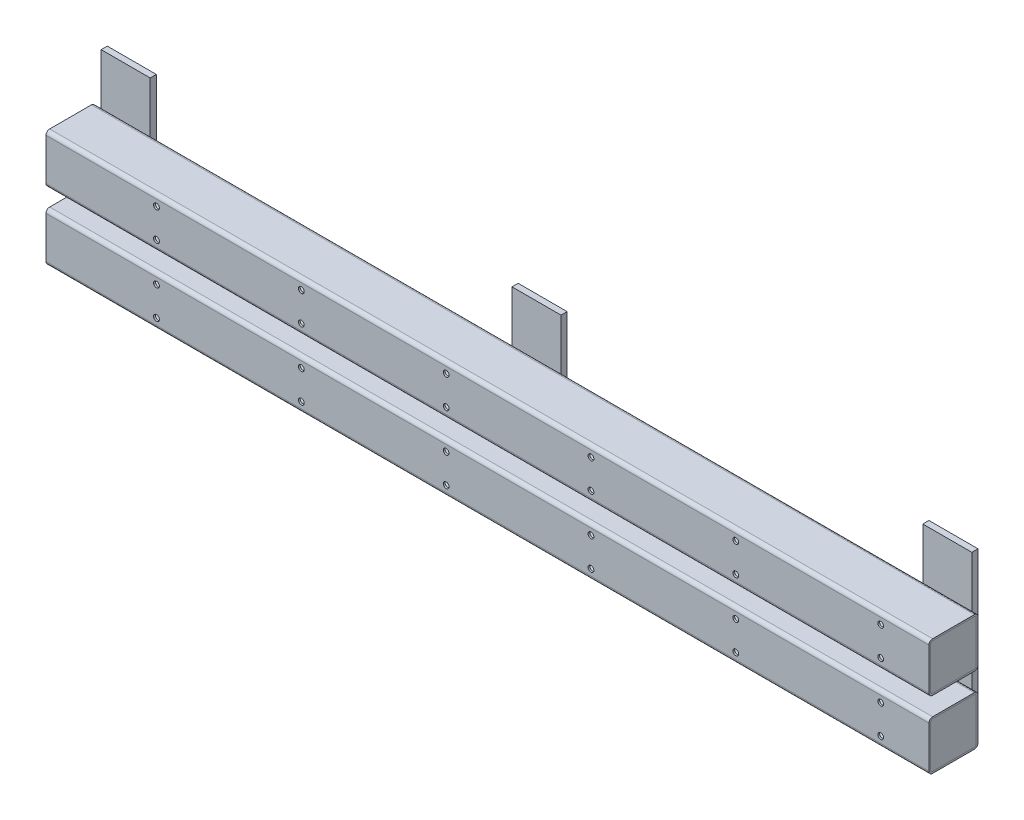
from build123d import *

# Parameters (mm, degrees)
F_2X2_SQUARE_TUBE_2X2X0_725_SQUARE_TUBE_1_DEPTH = 914.4
F_2X2_SQUARE_TUBE_2X2X0_725_SQUARE_TUB_2_DEPTH  = 914.4
BOSS_EXTRUDE1_DEPTH                             = 3
BOSS_EXTRUDE1_2_DEPTH                           = 3
BOSS_EXTRUDE4_DEPTH                             = 6.35
BOSS_EXTRUDE4_2_DEPTH                           = 6.35
SKETCH13_W                                      = 50.8
SKETCH13_H                                      = 171.6
BOSS_EXTRUDE3_DEPTH                             = 6.35
BOSS_EXTRUDE3_2_DEPTH                           = 6.35
BOSS_EXTRUDE3_3_DEPTH                           = 6.35
SKETCH16_R                                      = 3
CUT_EXTRUDE1_DEPTH                              = 1.8415
LPATTERN1_COUNT                                 = 6
LPATTERN1_PITCH                                 = 150
SKETCH18_R                                      = 3
CUT_EXTRUDE2_DEPTH                              = 3


with BuildPart() as part:
    # Sketch15 → 2x2 square tube 2X2X0.725 SQUARE TUBE(1) (new body)
    with BuildSketch(Plane(origin=(0, 70, 0), x_dir=(0, 1, 0), z_dir=(1, 0, 0))):
        with BuildLine():
            Line((-21.59, -25.4), (21.59, -25.4))
            ThreePointArc((21.59, -25.4), (24.284076836, -24.284076836), (25.4, -21.59))
            Line((25.4, -21.59), (25.4, 21.59))
            ThreePointArc((25.4, 21.59), (24.284076836, 24.284076836), (21.59, 25.4))
            Line((21.59, 25.4), (-21.59, 25.4))
            ThreePointArc((-21.59, 25.4), (-24.284076836, 24.284076836), (-25.4, 21.59))
            Line((-25.4, 21.59), (-25.4, -21.59))
            ThreePointArc((-25.4, -21.59), (-24.284076836, -24.284076836), (-21.59, -25.4))
        make_face()
        with BuildLine():
            Line((23.5585, -21.59), (23.5585, 21.59))
            ThreePointArc((23.5585, 21.59), (22.981939699, 22.981939699), (21.59, 23.5585))
            Line((21.59, 23.5585), (-21.59, 23.5585))
            ThreePointArc((-21.59, 23.5585), (-22.981939699, 22.981939699), (-23.5585, 21.59))
            Line((-23.5585, 21.59), (-23.5585, -21.59))
            ThreePointArc((-23.5585, -21.59), (-22.981939699, -22.981939699), (-21.59, -23.5585))
            Line((-21.59, -23.5585), (21.59, -23.5585))
            ThreePointArc((21.59, -23.5585), (22.981939699, -22.981939699), (23.5585, -21.59))
        make_face(mode=Mode.SUBTRACT)
    extrude(amount=F_2X2_SQUARE_TUBE_2X2X0_725_SQUARE_TUBE_1_DEPTH)


with BuildPart() as body_2:
    # Sketch15 on segment 2 (carried to segment 2) → 2x2 square tube 2X2X0.725 SQUARE TUB 2 (new body)
    with BuildSketch(Plane.YZ):
        with BuildLine():
            Line((-21.59, -25.4), (21.59, -25.4))
            ThreePointArc((21.59, -25.4), (24.284076836, -24.284076836), (25.4, -21.59))
            Line((25.4, -21.59), (25.4, 21.59))
            ThreePointArc((25.4, 21.59), (24.284076836, 24.284076836), (21.59, 25.4))
            Line((21.59, 25.4), (-21.59, 25.4))
            ThreePointArc((-21.59, 25.4), (-24.284076836, 24.284076836), (-25.4, 21.59))
            Line((-25.4, 21.59), (-25.4, -21.59))
            ThreePointArc((-25.4, -21.59), (-24.284076836, -24.284076836), (-21.59, -25.4))
        make_face()
        with BuildLine():
            Line((23.5585, -21.59), (23.5585, 21.59))
            ThreePointArc((23.5585, 21.59), (22.981939699, 22.981939699), (21.59, 23.5585))
            Line((21.59, 23.5585), (-21.59, 23.5585))
            ThreePointArc((-21.59, 23.5585), (-22.981939699, 22.981939699), (-23.5585, 21.59))
            Line((-23.5585, 21.59), (-23.5585, -21.59))
            ThreePointArc((-23.5585, -21.59), (-22.981939699, -22.981939699), (-21.59, -23.5585))
            Line((-21.59, -23.5585), (21.59, -23.5585))
            ThreePointArc((21.59, -23.5585), (22.981939699, -22.981939699), (23.5585, -21.59))
        make_face(mode=Mode.SUBTRACT)
    extrude(amount=F_2X2_SQUARE_TUBE_2X2X0_725_SQUARE_TUB_2_DEPTH)


with BuildPart() as body_3:
    # Sketch12 → Boss-Extrude1 (new body)
    with BuildSketch(Plane.ZY):
        with BuildLine():
            Line((-21.59, -23.5585), (21.59, -23.5585))
            ThreePointArc((21.59, -23.5585), (22.981939699, -22.981939699), (23.5585, -21.59))
            Line((23.5585, -21.59), (23.5585, 21.59))
            ThreePointArc((23.5585, 21.59), (22.981939699, 22.981939699), (21.59, 23.5585))
            Line((21.59, 23.5585), (-21.59, 23.5585))
            ThreePointArc((-21.59, 23.5585), (-22.981939699, 22.981939699), (-23.5585, 21.59))
            Line((-23.5585, 21.59), (-23.5585, -21.59))
            ThreePointArc((-23.5585, -21.59), (-22.981939699, -22.981939699), (-21.59, -23.5585))
        make_face()
    extrude(amount=-BOSS_EXTRUDE1_DEPTH)


with BuildPart() as body_4:
    # Sketch12 → Boss-Extrude1 2 (new body)
    with BuildSketch(Plane.ZY):
        with BuildLine():
            Line((-21.59, 46.4415), (21.59, 46.4415))
            ThreePointArc((21.59, 46.4415), (22.981939699, 47.018060301), (23.5585, 48.41))
            Line((23.5585, 48.41), (23.5585, 91.59))
            ThreePointArc((23.5585, 91.59), (22.981939699, 92.981939699), (21.59, 93.5585))
            Line((21.59, 93.5585), (-21.59, 93.5585))
            ThreePointArc((-21.59, 93.5585), (-22.981939699, 92.981939699), (-23.5585, 91.59))
            Line((-23.5585, 91.59), (-23.5585, 48.41))
            ThreePointArc((-23.5585, 48.41), (-22.981939699, 47.018060301), (-21.59, 46.4415))
        make_face()
    extrude(amount=-BOSS_EXTRUDE1_2_DEPTH)


with BuildPart() as body_5:
    # Sketch17 → Boss-Extrude4 (new body)
    with BuildSketch(Plane(origin=(914.4, 0, 0), x_dir=(0, 0, -1), z_dir=(1, 0, 0))):
        with BuildLine():
            Line((23.5585, -21.59), (23.5585, 21.59))
            ThreePointArc((23.5585, 21.59), (22.981939699, 22.981939699), (21.59, 23.5585))
            Line((21.59, 23.5585), (-21.59, 23.5585))
            ThreePointArc((-21.59, 23.5585), (-22.981939699, 22.981939699), (-23.5585, 21.59))
            Line((-23.5585, 21.59), (-23.5585, -21.59))
            ThreePointArc((-23.5585, -21.59), (-22.981939699, -22.981939699), (-21.59, -23.5585))
            Line((-21.59, -23.5585), (21.59, -23.5585))
            ThreePointArc((21.59, -23.5585), (22.981939699, -22.981939699), (23.5585, -21.59))
        make_face()
    extrude(amount=-BOSS_EXTRUDE4_DEPTH)


with BuildPart() as body_6:
    # Sketch17 → Boss-Extrude4 2 (new body)
    with BuildSketch(Plane(origin=(914.4, 0, 0), x_dir=(0, 0, -1), z_dir=(1, 0, 0))):
        with BuildLine():
            Line((23.5585, 48.41), (23.5585, 91.59))
            ThreePointArc((23.5585, 91.59), (22.981939699, 92.981939699), (21.59, 93.5585))
            Line((21.59, 93.5585), (-21.59, 93.5585))
            ThreePointArc((-21.59, 93.5585), (-22.981939699, 92.981939699), (-23.5585, 91.59))
            Line((-23.5585, 91.59), (-23.5585, 48.41))
            ThreePointArc((-23.5585, 48.41), (-22.981939699, 47.018060301), (-21.59, 46.4415))
            Line((-21.59, 46.4415), (21.59, 46.4415))
            ThreePointArc((21.59, 46.4415), (22.981939699, 47.018060301), (23.5585, 48.41))
        make_face()
    extrude(amount=-BOSS_EXTRUDE4_2_DEPTH)


with BuildPart() as body_7:
    # Sketch13 → Boss-Extrude3 (new body)
    with BuildSketch(Plane(origin=(0, 0, -25.4), x_dir=(-1, 0, 0), z_dir=(0, 0, -1))):
        with Locations((-882.649999999, 60.4)):
            Rectangle(SKETCH13_W, SKETCH13_H)
    extrude(amount=BOSS_EXTRUDE3_DEPTH)


with BuildPart() as body_8:
    # Sketch13 → Boss-Extrude3 2 (new body)
    with BuildSketch(Plane(origin=(0, 0, -25.4), x_dir=(-1, 0, 0), z_dir=(0, 0, -1))):
        with Locations((-457.2, 60.4)):
            Rectangle(SKETCH13_W, SKETCH13_H)
    extrude(amount=BOSS_EXTRUDE3_2_DEPTH)


with BuildPart() as body_9:
    # Sketch13 → Boss-Extrude3 3 (new body)
    with BuildSketch(Plane(origin=(0, 0, -25.4), x_dir=(-1, 0, 0), z_dir=(0, 0, -1))):
        with Locations((-31.75, 60.4)):
            Rectangle(SKETCH13_W, SKETCH13_H)
    extrude(amount=BOSS_EXTRUDE3_3_DEPTH)


with BuildPart() as cut_extrude1_tool:
    # Sketch16 → Cut-Extrude1 (new body)
    with BuildSketch(Plane.XY.offset(25.4)):
        with Locations((864.4, 85)):
            Circle(SKETCH16_R)
        with Locations((864.4, 55)):
            Circle(SKETCH16_R)
        with Locations((864.4, 15)):
            Circle(SKETCH16_R)
        with Locations((864.4, -15)):
            Circle(SKETCH16_R)
    cut_extrude1 = extrude(amount=-CUT_EXTRUDE1_DEPTH)


with BuildPart() as part_1:
    add(part.part)

    # Cut-Extrude1: cut by cut_extrude1_tool
    add(cut_extrude1_tool.part, mode=Mode.SUBTRACT)


with BuildPart() as body_2_1:
    add(body_2.part)

    # Cut-Extrude1: cut by cut_extrude1_tool
    add(cut_extrude1_tool.part, mode=Mode.SUBTRACT)


with BuildPart() as lpattern1_tool:
    # LPattern1: Cut-Extrude1 ×6
    with Locations(*[(-i * LPATTERN1_PITCH, 0, 0) for i in range(1, LPATTERN1_COUNT)]):
        add(cut_extrude1)


with BuildPart() as part_2:
    add(part_1.part)

    # LPattern1: cut by lpattern1_tool
    add(lpattern1_tool.part, mode=Mode.SUBTRACT)


with BuildPart() as body_2_2:
    add(body_2_1.part)

    # LPattern1: cut by lpattern1_tool
    add(lpattern1_tool.part, mode=Mode.SUBTRACT)


with BuildPart() as cut_extrude2_tool:
    # Sketch18 → Cut-Extrude2 (new body)
    with BuildSketch(Plane.ZY):
        with Locations((-12.7, -12.7)):
            Circle(SKETCH18_R)
        with Locations((-12.7, 12.7)):
            Circle(SKETCH18_R)
        with Locations((-12.7, 57.3)):
            Circle(SKETCH18_R)
        with Locations((-12.7, 82.7)):
            Circle(SKETCH18_R)
    extrude(amount=-CUT_EXTRUDE2_DEPTH)


with BuildPart() as body_3_1:
    add(body_3.part)

    # Cut-Extrude2: cut by cut_extrude2_tool
    add(cut_extrude2_tool.part, mode=Mode.SUBTRACT)


with BuildPart() as body_4_1:
    add(body_4.part)

    # Cut-Extrude2: cut by cut_extrude2_tool
    add(cut_extrude2_tool.part, mode=Mode.SUBTRACT)


solid = Compound([body_5.part, body_6.part, body_7.part, body_8.part, body_9.part, part_2.part, body_2_2.part, body_3_1.part, body_4_1.part])
